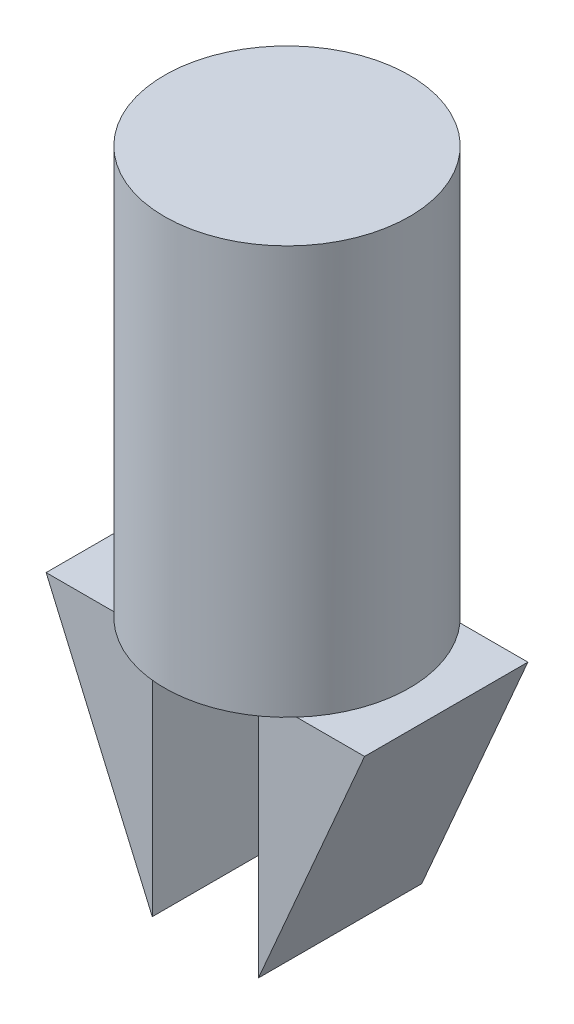
from build123d import *

# Parameters (mm, degrees)
SKETCH_1_R      = 15
EXTRUDE_1_DEPTH = 50
EXTRUDE_5_DEPTH = 10


with BuildPart() as part:
    # 草图1 → 凸台-拉伸1 (new body)
    with BuildSketch(Plane(origin=(0, 0, 0), x_dir=(1, 0, 0), z_dir=(0, 1, 0))):
        Circle(SKETCH_1_R)
    extrude(amount=EXTRUDE_1_DEPTH)

    # 草图6 → 凸台-拉伸5 (add, symmetric)
    with BuildSketch(Plane.XY):
        Polygon((-19.5, 0), (-6.5, -30), (-6.5, 0), align=None)
        Polygon((6.5, -30), (6.5, 0), (19.5, 0), align=None)
    extrude(amount=EXTRUDE_5_DEPTH, both=True)


solid = part.part
